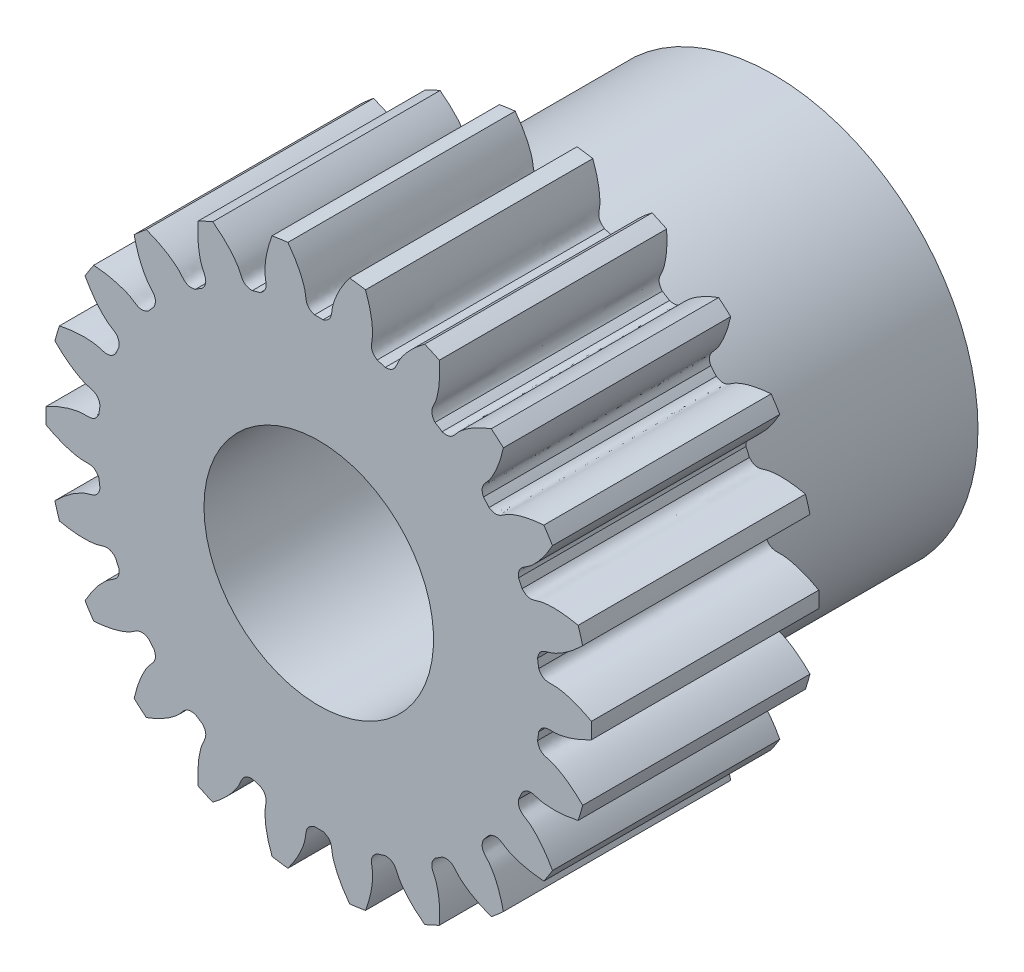
from build123d import *

# Parameters (mm, degrees)
SKETCH_1_R               = 12
EXTRUDE_1_DEPTH          = 10
CUT_EXTRUDE_1_DEPTH      = 20.697715604
PATTERN_CIRCULAR_1_COUNT = 22
SKETCH_4_R               = 9
EXTRUDE_2_DEPTH          = 10
SKETCH_5_R               = 5.05
CUT_EXTRUDE_2_DEPTH      = 27.194559786


with BuildPart() as part:
    # 草图1 → 凸台-拉伸1 (new body)
    with BuildSketch(Plane.XY):
        Circle(SKETCH_1_R)
    extrude(amount=EXTRUDE_1_DEPTH)

    # 草图2 → 切除-拉伸1 (cut, through all)
    with BuildSketch(Plane.XY):
        with BuildLine():
            ThreePointArc((0.185665431, 9.748232063), (0, 9.75), (-0.185665431, 9.748232063))
            add(Edge.make_bspline(
                [(-0.185665431, 9.748232063), (-0.588158706, 9.876186429), (-0.548347264, 10.151774696), (-0.599584047, 10.42157039), (-0.60596118, 10.451918903), (-0.613876897, 10.486162213), (-0.623483721, 10.524250431), (-0.634939934, 10.566127653), (-0.648399943, 10.611733662), (-0.664017171, 10.661003439), (-0.681942991, 10.713867378), (-0.70232689, 10.77025128), (-0.72531626, 10.830076418), (-0.751056303, 10.893259589), (-0.779689902, 10.959713172), (-0.811357505, 11.029345185), (-0.846197011, 11.10205935), (-0.884343649, 11.177755162), (-0.925929868, 11.25632795), (-0.971085225, 11.337668957), (-1.019936271, 11.421665408), (-1.072606448, 11.508200591), (-1.129215979, 11.597153935), (-1.189881763, 11.688401095), (-1.254717274, 11.781814033), (-1.323832459, 11.877261111), (-1.397333644, 11.974607178), (-1.475323431, 12.073713662), (-1.557900608, 12.174438668), (-1.64516006, 12.276637076), (-1.737192673, 12.380160638), (-1.834085256, 12.484858081), (-1.935920447, 12.590575215), (-2.042776642, 12.697155033), (-2.154727905, 12.804437827), (-2.271843904, 12.912261294), (-2.394189822, 13.020460649), (-2.521826308, 13.128868741), (-2.654809363, 13.237316171), (-2.841488127, 13.383435539), (-2.986445715, 13.489968103), (-3.085558798, 13.559868128)],
                knots=[0, 0, 0, 0, 0.157021319, 0.162530984, 0.168888289, 0.176093235, 0.184145822, 0.19304605, 0.202793918, 0.213389427, 0.224832576, 0.237123367, 0.250261798, 0.264247869, 0.279081582, 0.294762935, 0.311291928, 0.328668563, 0.346892838, 0.365964754, 0.38588431, 0.406651508, 0.428266346, 0.450728824, 0.474038944, 0.498196704, 0.523202104, 0.549055146, 0.575755828, 0.603304151, 0.631700114, 0.660943719, 0.691034964, 0.721973849, 0.753760376, 0.786394543, 0.819876351, 0.854205799, 0.889382888, 0.925407618, 1, 1, 1, 1], degree=3))
            ThreePointArc((-3.085558798, 13.559868128), (0, 13.906498364), (3.085558798, 13.559868128))
            add(Edge.make_bspline(
                [(0.185665431, 9.748232063), (0.588158706, 9.876186429), (0.548347264, 10.151774696), (0.599584047, 10.42157039), (0.60596118, 10.451918903), (0.613876897, 10.486162213), (0.623483721, 10.524250431), (0.634939934, 10.566127653), (0.648399943, 10.611733662), (0.664017171, 10.661003439), (0.681942991, 10.713867378), (0.70232689, 10.77025128), (0.72531626, 10.830076418), (0.751056303, 10.893259589), (0.779689902, 10.959713172), (0.811357505, 11.029345185), (0.846197011, 11.10205935), (0.884343649, 11.177755162), (0.925929868, 11.25632795), (0.971085225, 11.337668957), (1.019936271, 11.421665408), (1.072606448, 11.508200591), (1.129215979, 11.597153935), (1.189881763, 11.688401095), (1.254717274, 11.781814033), (1.323832459, 11.877261111), (1.397333644, 11.974607178), (1.475323431, 12.073713662), (1.557900608, 12.174438668), (1.64516006, 12.276637076), (1.737192673, 12.380160638), (1.834085256, 12.484858081), (1.935920447, 12.590575215), (2.042776642, 12.697155033), (2.154727905, 12.804437827), (2.271843904, 12.912261294), (2.394189822, 13.020460649), (2.521826308, 13.128868741), (2.654809363, 13.237316171), (2.841488127, 13.383435539), (2.986445715, 13.489968103), (3.085558798, 13.559868128)],
                knots=[0, 0, 0, 0, 0.157021319, 0.162530984, 0.168888289, 0.176093235, 0.184145822, 0.19304605, 0.202793918, 0.213389427, 0.224832576, 0.237123367, 0.250261798, 0.264247869, 0.279081582, 0.294762935, 0.311291928, 0.328668563, 0.346892838, 0.365964754, 0.38588431, 0.406651508, 0.428266346, 0.450728824, 0.474038944, 0.498196704, 0.523202104, 0.549055146, 0.575755828, 0.603304151, 0.631700114, 0.660943719, 0.691034964, 0.721973849, 0.753760376, 0.786394543, 0.819876351, 0.854205799, 0.889382888, 0.925407618, 1, 1, 1, 1], degree=3))
        make_face()
    cut_extrude_1 = extrude(amount=CUT_EXTRUDE_1_DEPTH, mode=Mode.SUBTRACT)

    # 阵列(圆周)1: 切除-拉伸1 ×22 about axis
    pattern_circular_1_axis = Axis((0, 0, -0.5), (0, 0, 1))
    for i in range(1, PATTERN_CIRCULAR_1_COUNT):
        add(cut_extrude_1.rotate(pattern_circular_1_axis, i * 360 / PATTERN_CIRCULAR_1_COUNT), mode=Mode.SUBTRACT)

    # 草图4 → 凸台-拉伸2 (add)
    with BuildSketch(Plane.XY):
        Circle(SKETCH_4_R)
    extrude(amount=-EXTRUDE_2_DEPTH)

    # 草图5 → 切除-拉伸2 (cut, through all)
    with BuildSketch(Plane(origin=(0, 0, -10), x_dir=(-1, 0, 0), z_dir=(0, 0, -1))):
        Circle(SKETCH_5_R)
    extrude(amount=-CUT_EXTRUDE_2_DEPTH, mode=Mode.SUBTRACT)


solid = part.part
